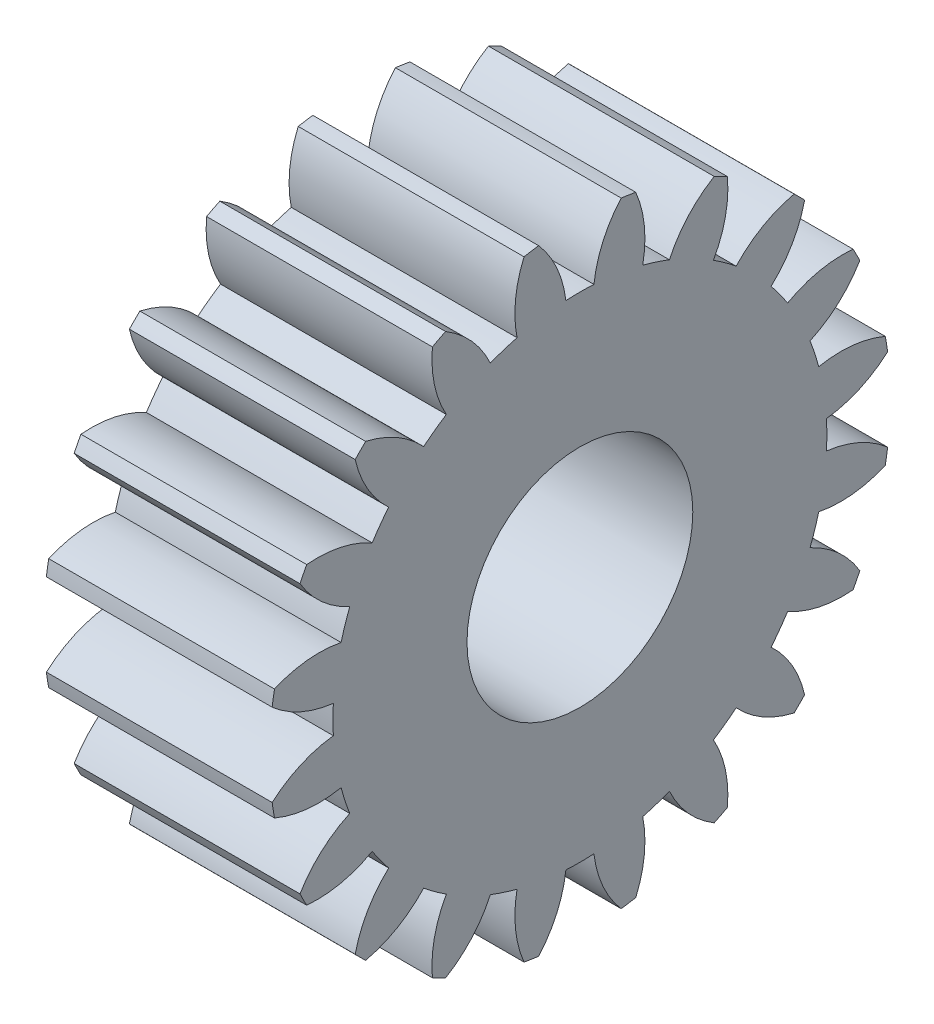
from build123d import *

# Parameters (mm, degrees)
BASPROSKE_W     = 12.7
BASPROSKE_H     = 17.4625
TOOTHCUT_DEPTH  = 28.769908399
TEETHCUTS_COUNT = 20
TEETHCUTS_ANGLE = 342
BORSKE_R        = 6.35
BORE_DEPTH      = 50.8000508


with BuildPart() as part:
    # BasProSke → Base-Revolve (revolve)
    with BuildSketch(Plane(origin=(0, 0, 0), x_dir=(1, 0, 0), z_dir=(0, 1, 0)), mode=Mode.PRIVATE) as base_revolve_sk:
        with Locations((6.35, 8.73125)):
            Rectangle(BASPROSKE_W, BASPROSKE_H)
    revolve(base_revolve_sk.sketch.rotate(Axis((-10, 0, 0), (1, 0, 0)), 180), axis=Axis((-10, 0, 0), (1, 0, 0)))

    # TooCutSke → ToothCut (cut, through all)
    with BuildSketch(Plane(origin=(0, 0, 0), x_dir=(0, 0, -1), z_dir=(1, 0, 0))):
        with BuildLine():
            ThreePointArc((0.788800759, 13.866938223), (0, 13.889355), (-0.788800759, 13.866938223))
            ThreePointArc((-0.788800759, 13.866938223), (-1.299448137, 15.717380814), (-2.339725589, 17.330675999))
            ThreePointArc((-2.339725589, 17.330675999), (0, 17.4879), (2.339725589, 17.330675999))
            ThreePointArc((2.339725589, 17.330675999), (1.299448137, 15.717380814), (0.788800759, 13.866938223))
        make_face()
    toothcut = extrude(amount=TOOTHCUT_DEPTH, mode=Mode.SUBTRACT)

    # TeethCuts: ToothCut ×20 about axis
    teethcuts_axis = Axis((-10, 0, 0), (1, 0, 0))
    for i in range(1, TEETHCUTS_COUNT):
        add(toothcut.rotate(teethcuts_axis, i * TEETHCUTS_ANGLE / (TEETHCUTS_COUNT - 1)), mode=Mode.SUBTRACT)

    # BorSke → Bore (cut, symmetric)
    with BuildSketch(Plane(origin=(0, 0, 0), x_dir=(0, 0, -1), z_dir=(1, 0, 0))):
        with Locations(Location((0, 0, 0), (0, 0, 180))):
            Circle(BORSKE_R)
    extrude(amount=BORE_DEPTH, both=True, mode=Mode.SUBTRACT)


solid = part.part
